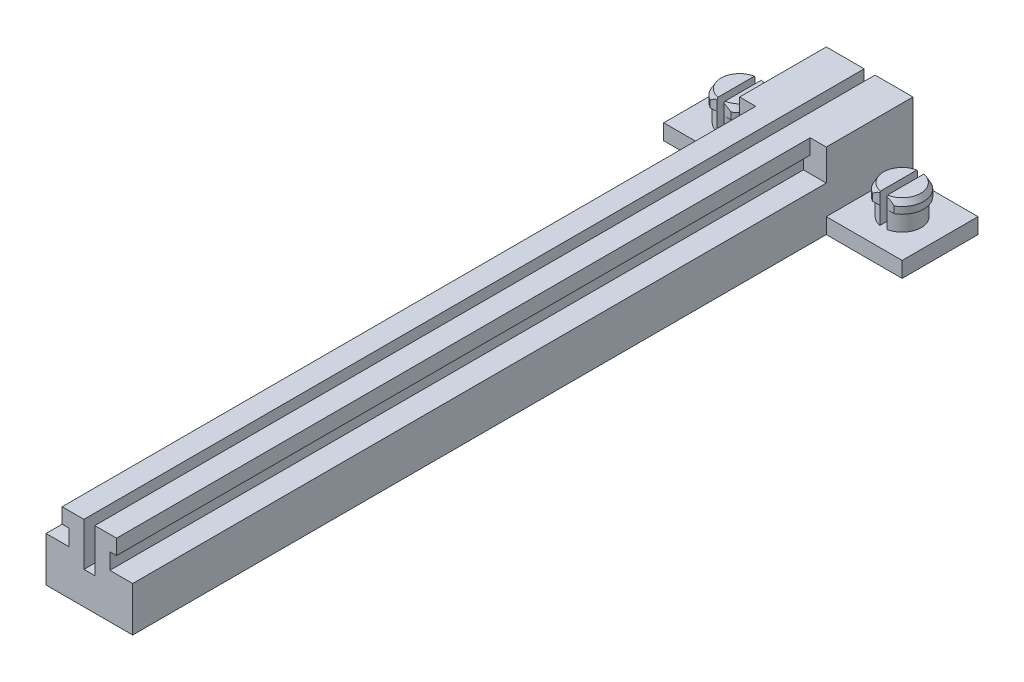
from build123d import *

# Parameters (mm, degrees)
SKETCH1_W             = 12.7
SKETCH1_H             = 114.3
BOSS_EXTRUDE1_DEPTH   = 11.1125
SKETCH2_W             = 1.5875
SKETCH2_H             = 6.35
CUT_EXTRUDE1_DEPTH    = 115.3
CUT_EXTRUDE2_DEPTH    = 101.6
SKETCH4_W             = 11.1125
SKETCH4_H             = 11.1125
BOSS_EXTRUDE2_DEPTH   = 2.286
BOSS_EXTRUDE3_DEPTH   = 2.54
BOSS_EXTRUDE5_DEPTH   = 1.778
CHAMFER1_SIZE         = 0.79375
CHAMFER1_SIZE2        = 0.458271776
CHAMFER1_PART_2_SIZE  = 0.79375
CHAMFER1_PART_2_SIZE2 = 0.458271776
CHAMFER1_PART_3_SIZE  = 0.79375
CHAMFER1_PART_3_SIZE2 = 0.458271776
CHAMFER1_PART_4_SIZE  = 0.79375
CHAMFER1_PART_4_SIZE2 = 0.458271776
SKETCH7_R             = 3.302
CUT_EXTRUDE3_DEPTH    = 2.032
SKETCH8_R             = 3.556
CUT_EXTRUDE4_DEPTH    = 1.905


with BuildPart() as part:
    # Sketch1 → Boss-Extrude1 (new body)
    with BuildSketch(Plane(origin=(0, 0, 0), x_dir=(1, 0, 0), z_dir=(0, 1, 0))):
        with Locations((6.35, -57.15)):
            Rectangle(SKETCH1_W, SKETCH1_H)
    extrude(amount=BOSS_EXTRUDE1_DEPTH)

    # Sketch2 → Cut-Extrude1 (cut, through all)
    with BuildSketch(Plane.XY.offset(114.3)):
        with Locations((6.35, 7.9375)):
            Rectangle(SKETCH2_W, SKETCH2_H)
    extrude(amount=-CUT_EXTRUDE1_DEPTH, mode=Mode.SUBTRACT)

    # Sketch3 → Cut-Extrude2 (cut)
    with BuildSketch(Plane.XY.offset(114.3)):
        Polygon((2.3622, 11.1125), (2.3622, 8.9027), (3.34645, 8.9027), (3.34645, 6.5405), (0, 6.5405), (0, 11.1125), align=None)
        Polygon((10.3378, 11.1125), (10.3378, 8.9027), (9.35355, 8.9027), (9.35355, 6.5405), (12.7, 6.5405), (12.7, 11.1125), align=None)
    extrude(amount=-CUT_EXTRUDE2_DEPTH, mode=Mode.SUBTRACT)

    # Sketch4 → Boss-Extrude2 (add)
    with BuildSketch(Plane.XZ):
        with Locations((-5.55625, 7.14375)):
            Rectangle(SKETCH4_W, SKETCH4_H)
        with Locations((18.25625, 7.14375)):
            Rectangle(SKETCH4_W, SKETCH4_H)
    extrude(amount=-BOSS_EXTRUDE2_DEPTH)

    # Sketch5 → Boss-Extrude3 (add)
    with BuildSketch(Plane(origin=(0, 2.286, 0), x_dir=(1, 0, 0), z_dir=(0, 1, 0))):
        with BuildLine():
            Line((18.76425, -4.396319928), (18.76425, -9.891180072))
            ThreePointArc((18.76425, -9.891180072), (21.05025, -7.14375), (18.76425, -4.396319928))
        make_face()
        with BuildLine():
            Line((-6.06425, -4.34975), (-6.06425, -9.93775))
            ThreePointArc((-6.06425, -9.93775), (-8.396056331, -7.14375), (-6.06425, -4.34975))
        make_face()
        with BuildLine():
            Line((17.74825, -4.396319928), (17.74825, -9.891180072))
            ThreePointArc((17.74825, -9.891180072), (15.46225, -7.14375), (17.74825, -4.396319928))
        make_face()
        with BuildLine():
            Line((-5.04825, -4.34975), (-5.04825, -9.93775))
            ThreePointArc((-5.04825, -9.93775), (-2.716443669, -7.14375), (-5.04825, -4.34975))
        make_face()
    extrude(amount=BOSS_EXTRUDE3_DEPTH)

    # Sketch6 → Boss-Extrude5 (add)
    with BuildSketch(Plane(origin=(0, 4.826, 0), x_dir=(1, 0, 0), z_dir=(0, 1, 0))):
        with BuildLine():
            Line((-7.064291445, -4.34975), (-6.06425, -4.34975))
            Line((-6.06425, -4.34975), (-6.06425, -9.93775))
            Line((-6.06425, -9.93775), (-7.064291445, -9.93775))
            ThreePointArc((-7.064291445, -9.93775), (-8.73125, -7.14375), (-7.064291445, -4.34975))
        make_face()
        with BuildLine():
            Line((-4.048208555, -4.34975), (-5.04825, -4.34975))
            Line((-5.04825, -4.34975), (-5.04825, -9.93775))
            Line((-5.04825, -9.93775), (-4.048208555, -9.93775))
            ThreePointArc((-4.048208555, -9.93775), (-2.38125, -7.14375), (-4.048208555, -4.34975))
        make_face()
        with BuildLine():
            Line((16.664944561, -4.396319928), (17.74825, -4.396319928))
            Line((17.74825, -4.396319928), (17.74825, -9.891180072))
            Line((17.74825, -9.891180072), (16.664944561, -9.891180072))
            ThreePointArc((16.664944561, -9.891180072), (15.08125, -7.14375), (16.664944561, -4.396319928))
        make_face()
        with BuildLine():
            Line((19.847555439, -4.396319928), (18.76425, -4.396319928))
            Line((18.76425, -4.396319928), (18.76425, -9.891180072))
            Line((18.76425, -9.891180072), (19.847555439, -9.891180072))
            ThreePointArc((19.847555439, -9.891180072), (21.43125, -7.14375), (19.847555439, -4.396319928))
        make_face()
    extrude(amount=BOSS_EXTRUDE5_DEPTH)

    # Chamfer1
    chamfer1_edges = [part.edges().sort_by_distance(p)[0] for p in [
        (21.43125, 6.604, 7.14375),
    ]]
    chamfer1_side = [part.faces().sort_by_distance(p)[0] for p in [
        (21.43125, 5.715, 7.14375),
    ]]
    chamfer(chamfer1_edges, length=CHAMFER1_SIZE, length2=CHAMFER1_SIZE2, reference=chamfer1_side[0])

    # Chamfer1 part 2
    chamfer1_part_2_edges = [part.edges().sort_by_distance(p)[0] for p in [
        (15.08125, 6.604, 7.14375),
    ]]
    chamfer1_part_2_side = [part.faces().sort_by_distance(p)[0] for p in [
        (15.08125, 5.715, 7.14375),
    ]]
    chamfer(chamfer1_part_2_edges, length=CHAMFER1_PART_2_SIZE, length2=CHAMFER1_PART_2_SIZE2, reference=chamfer1_part_2_side[0])

    # Chamfer1 part 3
    chamfer1_part_3_edges = [part.edges().sort_by_distance(p)[0] for p in [
        (-2.38125, 6.604, 7.14375),
    ]]
    chamfer1_part_3_side = [part.faces().sort_by_distance(p)[0] for p in [
        (-2.38125, 5.715, 7.14375),
    ]]
    chamfer(chamfer1_part_3_edges, length=CHAMFER1_PART_3_SIZE, length2=CHAMFER1_PART_3_SIZE2, reference=chamfer1_part_3_side[0])

    # Chamfer1 part 4
    chamfer1_part_4_edges = [part.edges().sort_by_distance(p)[0] for p in [
        (-8.73125, 6.604, 7.14375),
    ]]
    chamfer1_part_4_side = [part.faces().sort_by_distance(p)[0] for p in [
        (-8.73125, 5.715, 7.14375),
    ]]
    chamfer(chamfer1_part_4_edges, length=CHAMFER1_PART_4_SIZE, length2=CHAMFER1_PART_4_SIZE2, reference=chamfer1_part_4_side[0])

    # Sketch7 → Cut-Extrude3 (cut)
    with BuildSketch(Plane.XZ):
        with Locations((6.35, 101.6)):
            Circle(SKETCH7_R)
        with Locations((6.35, 44.014136)):
            Circle(SKETCH7_R)
    extrude(amount=-CUT_EXTRUDE3_DEPTH, mode=Mode.SUBTRACT)

    # Sketch8 → Cut-Extrude4 (cut)
    with BuildSketch(Plane.XZ.offset(-2.032)):
        with Locations((6.35, 101.6)):
            Circle(SKETCH8_R)
        with Locations((6.35, 44.014136)):
            Circle(SKETCH8_R)
    extrude(amount=-CUT_EXTRUDE4_DEPTH, mode=Mode.SUBTRACT)


solid = part.part
